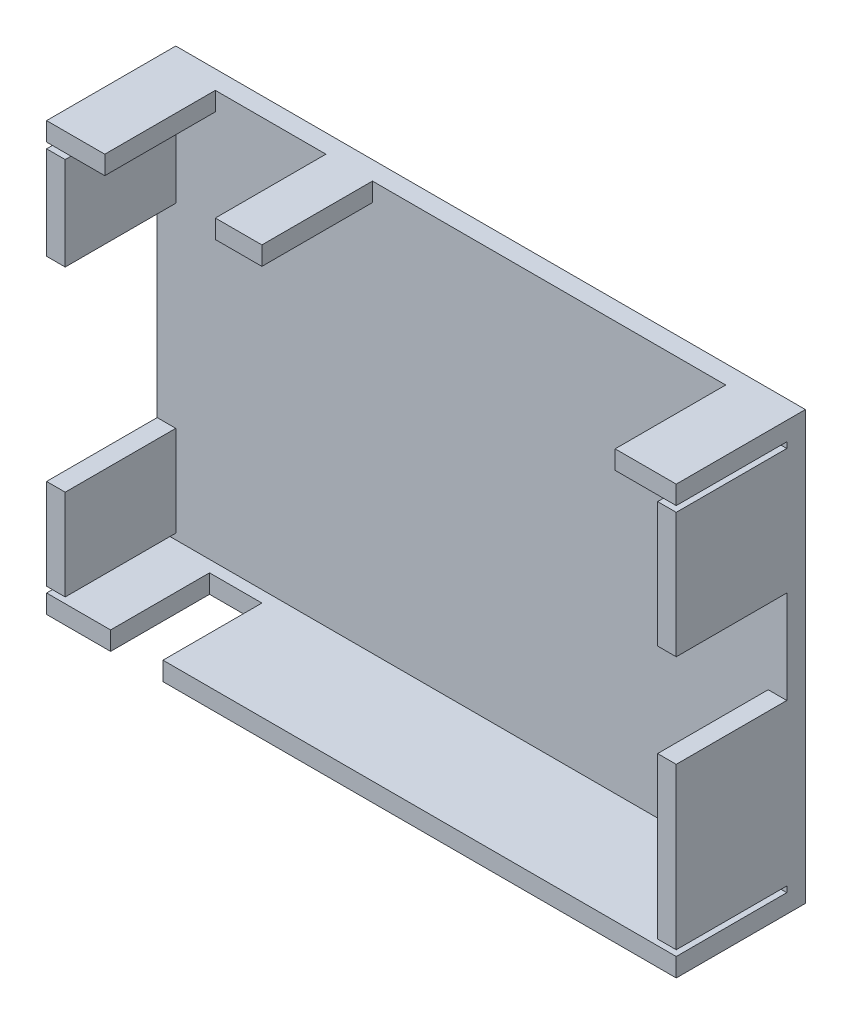
from build123d import *

# Parameters (mm, degrees)
SKETCH1_W           = 108.2
SKETCH1_H           = 73.5
BOSS_EXTRUDE2_DEPTH = 3.2
SKETCH2_W           = 108.2
SKETCH2_H           = 73.5
SKETCH2_W_2         = 101.8
SKETCH2_H_2         = 67.1
BOSS_EXTRUDE3_DEPTH = 19
SKETCH3_W           = 3.2
SKETCH3_H           = 1
CUT_EXTRUDE1_DEPTH  = 19
SKETCH4_W           = 3.2
SKETCH4_H           = 33.5
CUT_EXTRUDE2_DEPTH  = 19
SKETCH5_W           = 19
SKETCH5_H           = 3.2
SKETCH5_W_2         = 60.7
CUT_EXTRUDE3_DEPTH  = 19
SKETCH6_W           = 3.2
SKETCH6_H           = 16
CUT_EXTRUDE4_DEPTH  = 19
SKETCH7_W           = 9
SKETCH7_H           = 3.2
CUT_EXTRUDE5_DEPTH  = 17


with BuildPart() as part:
    # Sketch1 → Boss-Extrude2 (new body)
    with BuildSketch(Plane.XY):
        with Locations((54.1, 36.75)):
            Rectangle(SKETCH1_W, SKETCH1_H)
    extrude(amount=BOSS_EXTRUDE2_DEPTH)

    # Sketch2 → Boss-Extrude3 (add)
    with BuildSketch(Plane.XY.offset(3.2)):
        with Locations((54.1, 36.75)):
            Rectangle(SKETCH2_W, SKETCH2_H)
        with Locations((54.1, 36.75)):
            Rectangle(SKETCH2_W_2, SKETCH2_H_2, mode=Mode.SUBTRACT)
    extrude(amount=BOSS_EXTRUDE3_DEPTH)

    # Sketch3 → Cut-Extrude1 (cut)
    with BuildSketch(Plane.XY.offset(22.2)):
        with Locations((1.6, 69.8)):
            Rectangle(SKETCH3_W, SKETCH3_H)
        with Locations((106.6, 69.8)):
            Rectangle(SKETCH3_W, SKETCH3_H)
        with Locations((106.6, 3.7)):
            Rectangle(SKETCH3_W, SKETCH3_H)
        with Locations((1.6, 3.7)):
            Rectangle(SKETCH3_W, SKETCH3_H)
    extrude(amount=-CUT_EXTRUDE1_DEPTH, mode=Mode.SUBTRACT)

    # Sketch4 → Cut-Extrude2 (cut)
    with BuildSketch(Plane.XY.offset(22.2)):
        with Locations((1.6, 36.55)):
            Rectangle(SKETCH4_W, SKETCH4_H)
    extrude(amount=-CUT_EXTRUDE2_DEPTH, mode=Mode.SUBTRACT)

    # Sketch5 → Cut-Extrude3 (cut)
    with BuildSketch(Plane.XY.offset(22.2)):
        with Locations((19.5, 71.9)):
            Rectangle(SKETCH5_W, SKETCH5_H)
        with Locations((67.35, 71.9)):
            Rectangle(SKETCH5_W_2, SKETCH5_H)
    extrude(amount=-CUT_EXTRUDE3_DEPTH, mode=Mode.SUBTRACT)

    # Sketch6 → Cut-Extrude4 (cut)
    with BuildSketch(Plane.XY.offset(22.2)):
        with Locations((106.6, 39.8)):
            Rectangle(SKETCH6_W, SKETCH6_H)
    extrude(amount=-CUT_EXTRUDE4_DEPTH, mode=Mode.SUBTRACT)

    # Sketch7 → Cut-Extrude5 (cut)
    with BuildSketch(Plane.XY.offset(22.2)):
        with Locations((15.5, 1.6)):
            Rectangle(SKETCH7_W, SKETCH7_H)
    extrude(amount=-CUT_EXTRUDE5_DEPTH, mode=Mode.SUBTRACT)


solid = part.part
